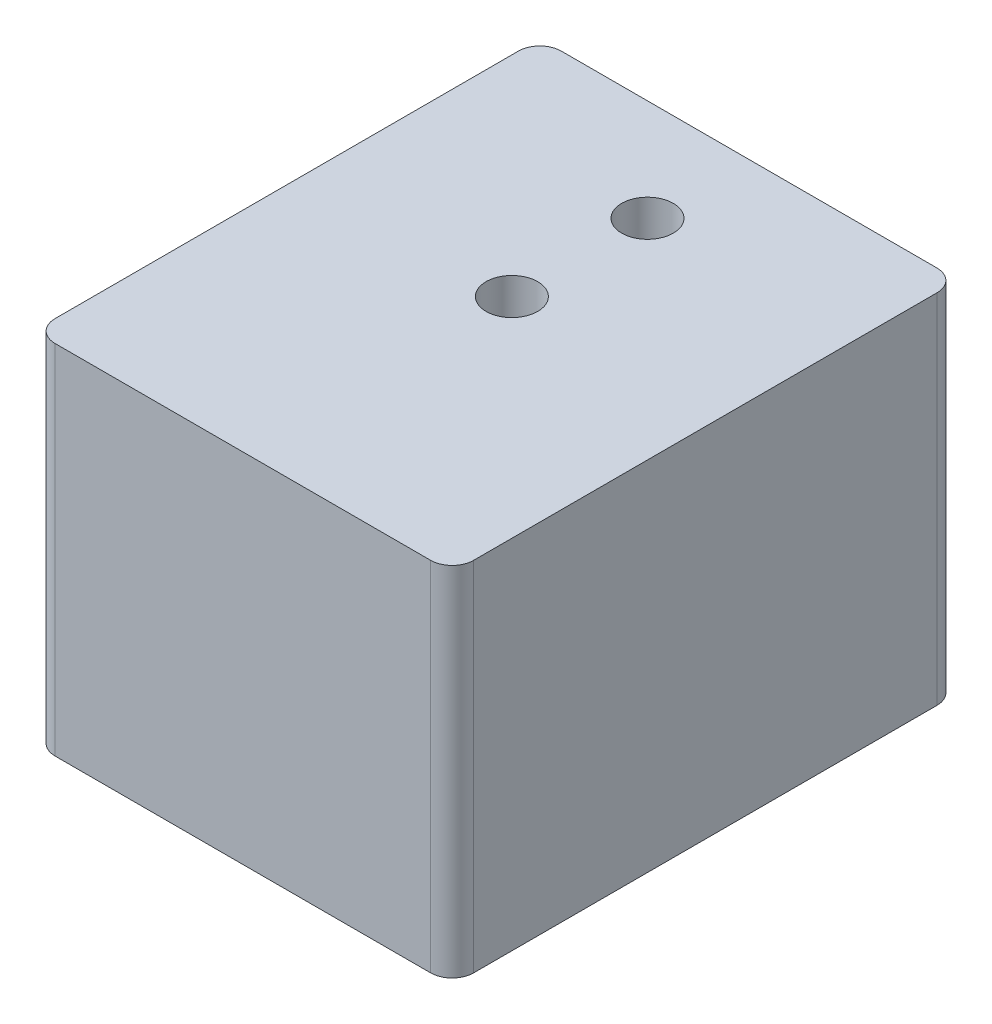
from build123d import *

# Parameters (mm, degrees)
SKETCH1_W           = 24.699999876
SKETCH1_H           = 29.87499994
SKETCH1_R           = 1.524
BOSS_EXTRUDE1_DEPTH = 21.082
FILLET1_R           = 1.27


with BuildPart() as part:
    # Sketch1 → Boss-Extrude1 (new body)
    with BuildSketch(Plane(origin=(0, 0, 0), x_dir=(1, 0, 0), z_dir=(0, 1, 0))):
        with Locations((12.349999938, 14.93749997)):
            Rectangle(SKETCH1_W, SKETCH1_H)
        with Locations((12.349999938, 15.875)):
            Circle(SKETCH1_R, mode=Mode.SUBTRACT)
        with Locations((12.349999938, 23.875000002)):
            Circle(SKETCH1_R, mode=Mode.SUBTRACT)
    extrude(amount=BOSS_EXTRUDE1_DEPTH)

    # Fillet1
    fillet1_edges = [part.edges().sort_by_distance(p)[0] for p in [
        (0, 10.541, -29.87499994),
        (24.699999876, 10.541, -29.87499994),
        (24.699999876, 10.541, 0),
        (0, 10.541, 0),
    ]]
    fillet(fillet1_edges, radius=FILLET1_R)


solid = part.part
